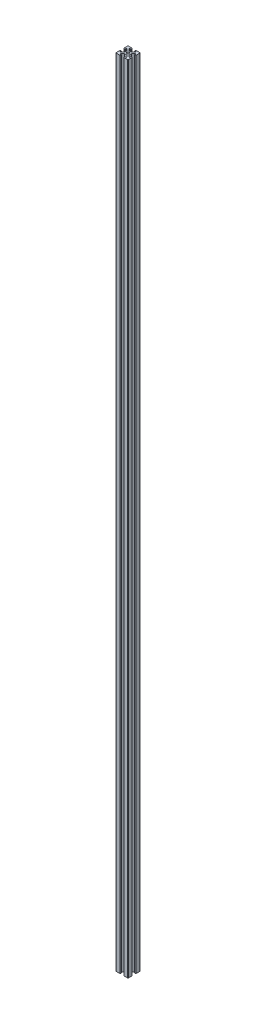
from build123d import *

# Parameters (mm, degrees)
SKETCH_1_R      = 2.1
EXTRUDE_1_DEPTH = 1300


with BuildPart() as part:
    # 스케치1 → 보스-돌출1 (new body)
    with BuildSketch(Plane(origin=(0, 0, 0), x_dir=(1, 0, 0), z_dir=(0, 1, 0))):
        with BuildLine():
            Line((2, -4), (-2, -4))
            Line((-2, -4), (-5, -7))
            Line((-5, -7), (-5, -7.5))
            ThreePointArc((-5, -7.5), (-4.853553391, -7.853553391), (-4.5, -8))
            Line((-4.5, -8), (-3.1, -8))
            ThreePointArc((-3.1, -8), (-2.746446609, -8.146446609), (-2.6, -8.5))
            Line((-2.6, -8.5), (-2.6, -9.5))
            Line((-2.6, -9.5), (-3.1, -9.5))
            Line((-3.1, -9.5), (-3.1, -10))
            Line((-3.1, -10), (-9, -10))
            ThreePointArc((-9, -10), (-9.382683432, -9.923879533), (-9.707106781, -9.707106781))
            ThreePointArc((-9.707106781, -9.707106781), (-9.923879533, -9.382683432), (-10, -9))
            Line((-10, -9), (-10, -3.1))
            Line((-10, -3.1), (-9.5, -3.1))
            Line((-9.5, -3.1), (-9.5, -2.6))
            Line((-9.5, -2.6), (-8.5, -2.6))
            ThreePointArc((-8.5, -2.6), (-8.146446609, -2.746446609), (-8, -3.1))
            Line((-8, -3.1), (-8, -4.5))
            ThreePointArc((-8, -4.5), (-7.853553391, -4.853553391), (-7.5, -5))
            Line((-7.5, -5), (-7, -5))
            Line((-7, -5), (-4, -2))
            Line((-4, -2), (-4, 2))
            Line((-4, 2), (-7, 5))
            Line((-7, 5), (-7.5, 5))
            ThreePointArc((-7.5, 5), (-7.853553391, 4.853553391), (-8, 4.5))
            Line((-8, 4.5), (-8, 3.1))
            ThreePointArc((-8, 3.1), (-8.146446609, 2.746446609), (-8.5, 2.6))
            Line((-8.5, 2.6), (-9.5, 2.6))
            Line((-9.5, 2.6), (-9.5, 3.1))
            Line((-9.5, 3.1), (-10, 3.1))
            Line((-10, 3.1), (-10, 9))
            ThreePointArc((-10, 9), (-9.923879533, 9.382683432), (-9.707106781, 9.707106781))
            ThreePointArc((-9.707106781, 9.707106781), (-9.382683432, 9.923879533), (-9, 10))
            Line((-9, 10), (-3.1, 10))
            Line((-3.1, 10), (-3.1, 9.5))
            Line((-3.1, 9.5), (-2.6, 9.5))
            Line((-2.6, 9.5), (-2.6, 8.5))
            ThreePointArc((-2.6, 8.5), (-2.746446609, 8.146446609), (-3.1, 8))
            Line((-3.1, 8), (-4.5, 8))
            ThreePointArc((-4.5, 8), (-4.853553391, 7.853553391), (-5, 7.5))
            Line((-5, 7.5), (-5, 7))
            Line((-5, 7), (-2, 4))
            Line((-2, 4), (2, 4))
            Line((2, 4), (5, 7))
            Line((5, 7), (5, 7.5))
            ThreePointArc((5, 7.5), (4.853553391, 7.853553391), (4.5, 8))
            Line((4.5, 8), (3.1, 8))
            ThreePointArc((3.1, 8), (2.746446609, 8.146446609), (2.6, 8.5))
            Line((2.6, 8.5), (2.6, 9.5))
            Line((2.6, 9.5), (3.1, 9.5))
            Line((3.1, 9.5), (3.1, 10))
            Line((3.1, 10), (9, 10))
            ThreePointArc((9, 10), (9.382683432, 9.923879533), (9.707106781, 9.707106781))
            ThreePointArc((9.707106781, 9.707106781), (9.923879533, 9.382683432), (10, 9))
            Line((10, 9), (10, 3.1))
            Line((10, 3.1), (9.5, 3.1))
            Line((9.5, 3.1), (9.5, 2.6))
            Line((9.5, 2.6), (8.5, 2.6))
            ThreePointArc((8.5, 2.6), (8.146446609, 2.746446609), (8, 3.1))
            Line((8, 3.1), (8, 4.5))
            ThreePointArc((8, 4.5), (7.853553391, 4.853553391), (7.5, 5))
            Line((7.5, 5), (7, 5))
            Line((7, 5), (4, 2))
            Line((4, 2), (4, -2))
            Line((4, -2), (7, -5))
            Line((7, -5), (7.5, -5))
            ThreePointArc((7.5, -5), (7.853553391, -4.853553391), (8, -4.5))
            Line((8, -4.5), (8, -3.1))
            ThreePointArc((8, -3.1), (8.146446609, -2.746446609), (8.5, -2.6))
            Line((8.5, -2.6), (9.5, -2.6))
            Line((9.5, -2.6), (9.5, -3.1))
            Line((9.5, -3.1), (10, -3.1))
            Line((10, -3.1), (10, -9))
            ThreePointArc((10, -9), (9.923879533, -9.382683432), (9.707106781, -9.707106781))
            ThreePointArc((9.707106781, -9.707106781), (9.382683432, -9.923879533), (9, -10))
            Line((9, -10), (3.1, -10))
            Line((3.1, -10), (3.1, -9.5))
            Line((3.1, -9.5), (2.6, -9.5))
            Line((2.6, -9.5), (2.6, -8.5))
            ThreePointArc((2.6, -8.5), (2.746446609, -8.146446609), (3.1, -8))
            Line((3.1, -8), (4.5, -8))
            ThreePointArc((4.5, -8), (4.853553391, -7.853553391), (5, -7.5))
            Line((5, -7.5), (5, -7))
            Line((5, -7), (2, -4))
        make_face()
        Circle(SKETCH_1_R, mode=Mode.SUBTRACT)
    extrude(amount=EXTRUDE_1_DEPTH)


solid = part.part
